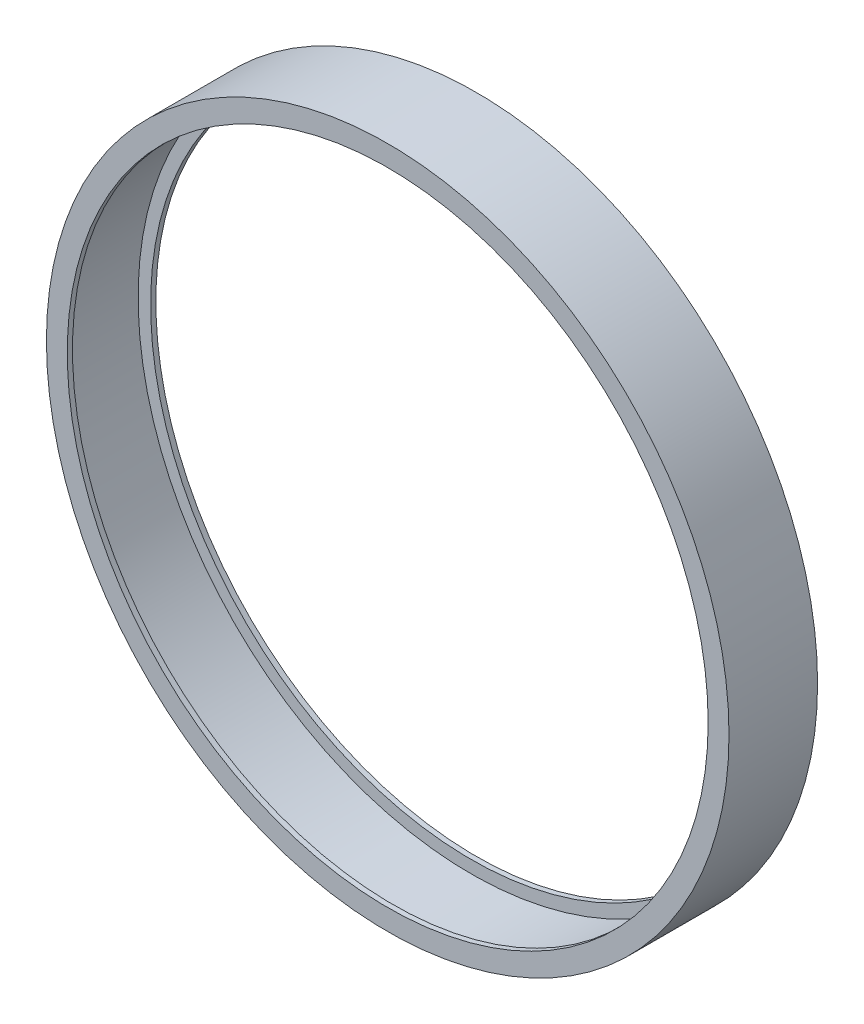
from build123d import *


with BuildPart() as part:
    # Sketch4 → Revolve1 (revolve)
    with BuildSketch(Plane(origin=(0, 0, 0), x_dir=(0, 0, -1), z_dir=(1, 0, 0))):
        Polygon((0, 0), (8.5, 0), (8.5, -2), (8, -2), (8, -0.8), (0.5, -0.8), (0.5, -2), (0, -2), align=None)
    revolve(axis=Axis((0, -32.75, 15.468296477), (0, 0, -1)))


solid = part.part
